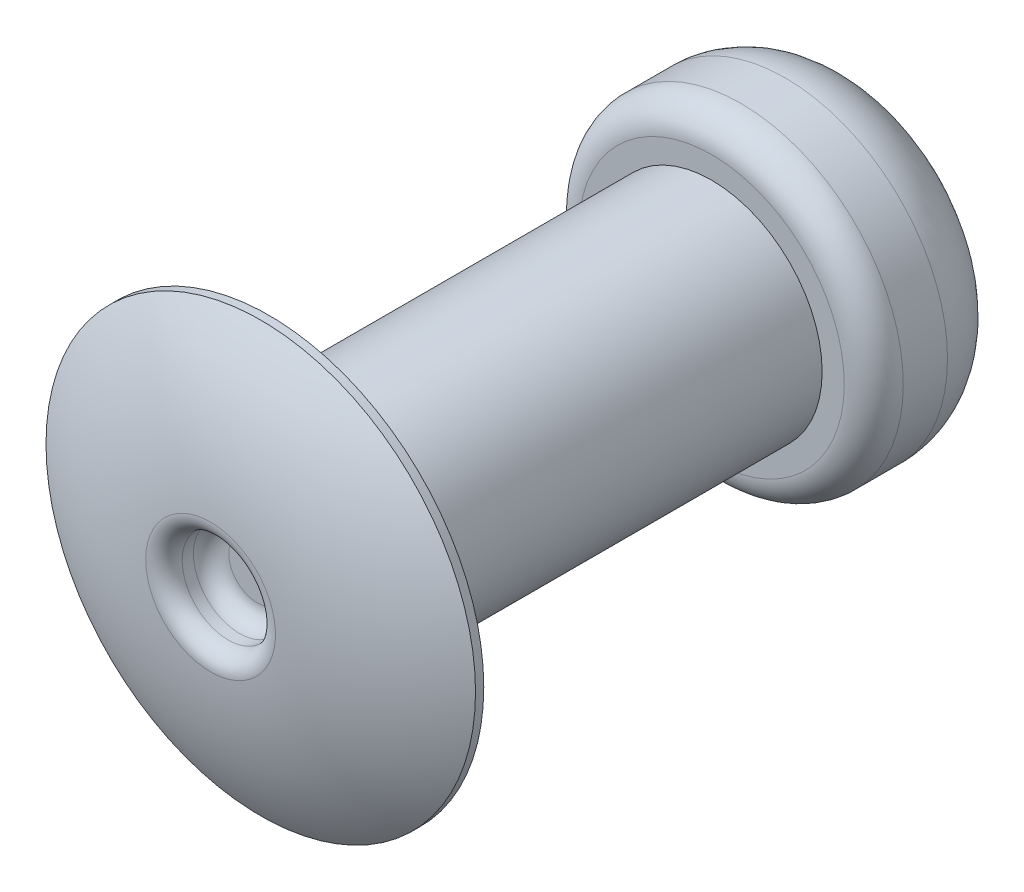
from build123d import *
from OCP.BRepFilletAPI import BRepFilletAPI_MakeFillet

# Parameters (mm, degrees)
SKETCH4_R          = 0.9921875
CUT_EXTRUDE1_DEPTH = 1.016
CUT_EXTRUDE2_START = -2.54
SKETCH3_R          = 0.9921875
CUT_EXTRUDE2_DEPTH = 2.54
FILLET1_R1         = 0.635
FILLET1_R2         = 1.5875
FILLET1_R3         = 0.381


with BuildPart() as part:
    # Sketch2 → Revolve1 (revolve)
    with BuildSketch(Plane(origin=(0, 0, 0), x_dir=(0, 0, -1), z_dir=(1, 0, 0))):
        with BuildLine():
            Line((-1.27, 0.9921875), (-1.27, 0))
            Line((-1.27, 0), (9.525, 0))
            Line((9.525, 0), (12.7, 0))
            Line((12.7, 0), (12.7, 3.4925))
            Line((12.7, 3.4925), (9.525, 3.4925))
            Line((9.525, 3.4925), (9.525, 2.38125))
            Line((9.525, 2.38125), (0, 2.38125))
            Line((0, 2.38125), (0, 4.6228))
            Line((0, 4.6228), (-0.1778, 4.6228))
            ThreePointArc((-0.1778, 4.6228), (-0.991036966, 2.887856773), (-1.27, 0.9921875))
        make_face()
    revolve(axis=Axis((0, 0, 7.600580616), (0, 0, 1)))

    # Sketch4 → Cut-Extrude1 (cut)
    with BuildSketch(Plane.XY.offset(1.27)):
        Circle(SKETCH4_R)
    extrude(amount=-CUT_EXTRUDE1_DEPTH, mode=Mode.SUBTRACT)

    # Sketch3 → Cut-Extrude2 (cut)
    with BuildSketch(Plane(origin=(0, 0, -12.7), x_dir=(-1, 0, 0), z_dir=(0, 0, -1)).offset(CUT_EXTRUDE2_START)):
        Circle(SKETCH3_R)
    extrude(amount=CUT_EXTRUDE2_DEPTH, mode=Mode.SUBTRACT)

    # Fillet1: one fillet with a radius per group of edges: ONE call of the kernel's fillet builder (fillet() takes one radius for all edges)
    fillet1_edges_1 = [part.edges().sort_by_distance(p)[0] for p in [
        (0, -3.4925, -9.525),
    ]]
    fillet1_edges_2 = [part.edges().sort_by_distance(p)[0] for p in [
        (0, -3.4925, -12.7),
    ]]
    fillet1_edges_3 = [part.edges().sort_by_distance(p)[0] for p in [
        (0, -2.38125, 0),
        (-0.701582509, -0.701582509, 1.27),
        (-0.9921875, 0, 0.254),
    ]]
    fillet1 = BRepFilletAPI_MakeFillet(part.part.solid().wrapped)
    for e in fillet1_edges_1:
        fillet1.Add(FILLET1_R1, e.wrapped)
    for e in fillet1_edges_2:
        fillet1.Add(FILLET1_R2, e.wrapped)
    for e in fillet1_edges_3:
        fillet1.Add(FILLET1_R3, e.wrapped)
    add(Compound.cast(fillet1.Shape()), mode=Mode.REPLACE)


solid = part.part
